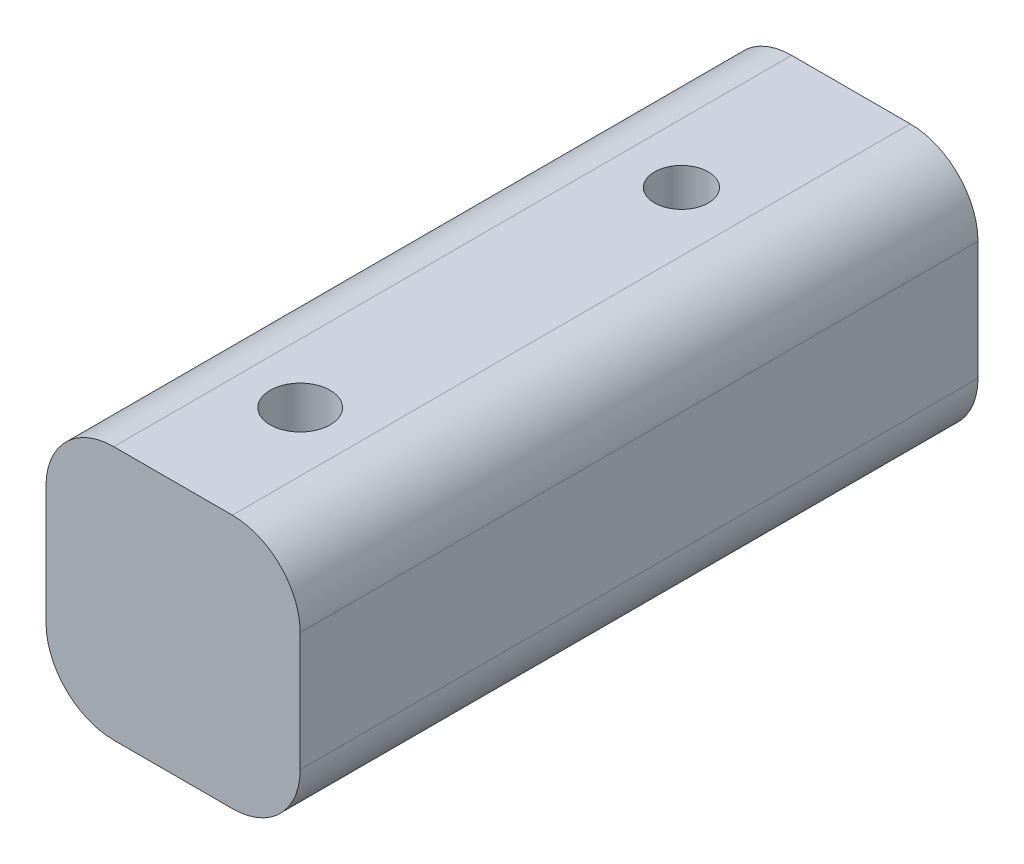
from build123d import *

# Parameters (mm, degrees)
SKETCH1_W              = 19.05
SKETCH1_H              = 19.05
BOSS_EXTRUDE1_DEPTH    = 50.8
CUT_EXTRUDE1_DEPTH     = 12.7
F_8_CLEARANCE_HOLE1_D  = 4.4958
FILLET1_R              = 0.381
F_10_32_TAPPED_HOLE1_D = 4.0386
FILLET2_R              = 5.08


with BuildPart() as part:
    # Sketch1 → Boss-Extrude1 (new body)
    with BuildSketch(Plane.XY):
        Rectangle(SKETCH1_W, SKETCH1_H)
    extrude(amount=BOSS_EXTRUDE1_DEPTH)

    # Sketch2 → Cut-Extrude1 (cut)
    with BuildSketch(Plane.XZ.offset(9.525)):
        with BuildLine():
            Line((-0.79375, 47.625), (0.79375, 47.625))
            ThreePointArc((0.79375, 47.625), (3.03881403, 46.69506403), (3.96875, 44.45))
            Line((3.96875, 44.45), (3.96875, 38.1))
            ThreePointArc((3.96875, 38.1), (3.03881403, 35.85493597), (0.79375, 34.925))
            Line((0.79375, 34.925), (-0.79375, 34.925))
            ThreePointArc((-0.79375, 34.925), (-3.03881403, 35.85493597), (-3.96875, 38.1))
            Line((-3.96875, 38.1), (-3.96875, 44.45))
            ThreePointArc((-3.96875, 44.45), (-3.03881403, 46.69506403), (-0.79375, 47.625))
        make_face()
    extrude(amount=-CUT_EXTRUDE1_DEPTH, mode=Mode.SUBTRACT)

    # #8 Clearance Hole1 (through all)
    with Locations(Plane(origin=(0, 3.175, 0), x_dir=(-1, 0, 0), z_dir=(0, -1, 0))):
        with Locations((0, -41.275)):
            Hole(F_8_CLEARANCE_HOLE1_D / 2)

    # Fillet1
    fillet1_edges = [part.edges().sort_by_distance(p)[0] for p in [
        (0, -9.525, 47.625),
        (3.96875, -9.525, 41.275),
        (-3.03881403, -9.525, 46.69506403),
        (-3.96875, -9.525, 41.275),
        (-3.03881403, -9.525, 35.85493597),
        (0, -9.525, 34.925),
        (3.03881403, -9.525, 35.85493597),
        (3.03881403, -9.525, 46.69506403),
    ]]
    fillet(fillet1_edges, radius=FILLET1_R)

    # #10-32 Tapped Hole1 (through all)
    with Locations(Plane(origin=(0, 9.525, 0), x_dir=(1, 0, 0), z_dir=(0, 1, 0))):
        with Locations((0, -12.7)):
            Hole(F_10_32_TAPPED_HOLE1_D / 2)

    # Fillet2
    fillet2_edges = [part.edges().sort_by_distance(p)[0] for p in [
        (9.525, -9.525, 25.4),
        (-9.525, -9.525, 25.4),
        (-9.525, 9.525, 25.4),
        (9.525, 9.525, 25.4),
    ]]
    fillet(fillet2_edges, radius=FILLET2_R)


solid = part.part
